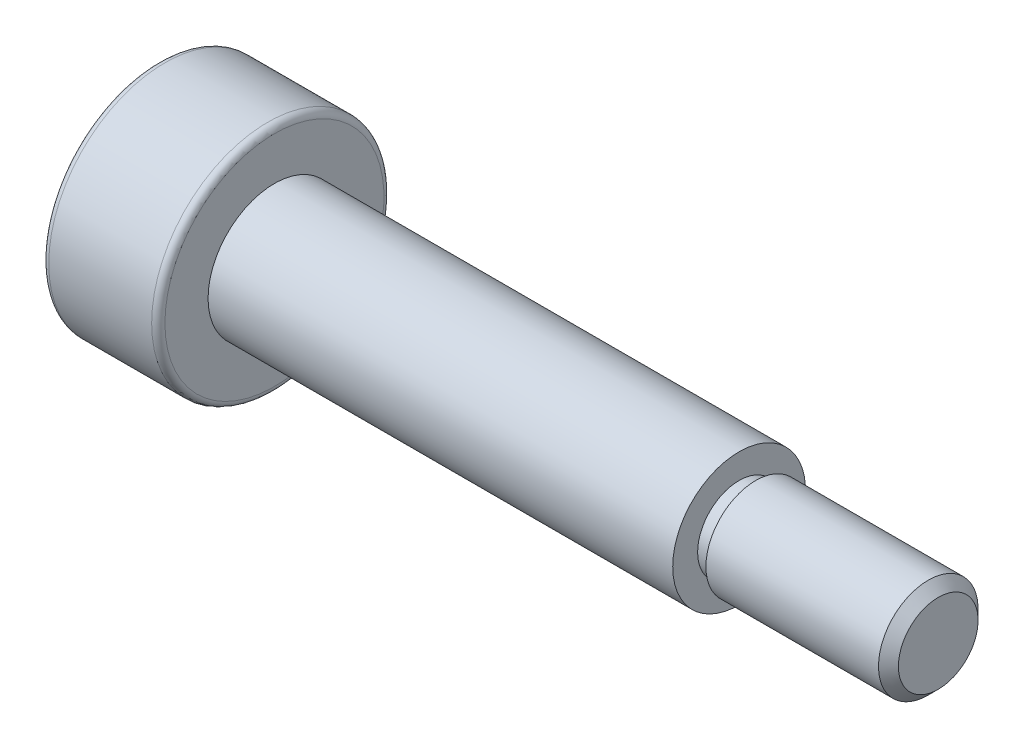
from build123d import *

# Parameters (mm, degrees)
FILLET_1_R          = 0.2
CHAMFER_1_SIZE      = 0.3
SKETCH_3_W          = 0.5
SKETCH_3_H          = 0.25
CUT_EXTRUDE_1_DEPTH = 2


with BuildPart() as part:
    # 草图1 → 旋转1 (revolve)
    with BuildSketch(Plane.XY):
        Polygon((-11.75, 0), (-11.75, 3.5), (-8.25, 3.5), (-8.25, 2), (5.75, 2), (5.75, 1.5), (11.75, 1.5), (11.75, 0), align=None)
    revolve(axis=Axis((-11.75, 0, 0), (1, 0, 0)))

    # 圆角1
    fillet_1_edges = [part.edges().sort_by_distance(p)[0] for p in [
        (-8.25, -3.5, 0),
        (-11.75, -3.5, 0),
    ]]
    fillet(fillet_1_edges, radius=FILLET_1_R)

    # 倒角1
    chamfer_1_edges = [part.edges().sort_by_distance(p)[0] for p in [
        (11.75, -1.5, 0),
    ]]
    chamfer(chamfer_1_edges, length=CHAMFER_1_SIZE)

    # 草图3 → 切除-旋转1 (revolve, cut)
    with BuildSketch(Plane.XY):
        with Locations((6, 1.375)):
            Rectangle(SKETCH_3_W, SKETCH_3_H)
    revolve(axis=Axis((5.75, 0, 0), (1, 0, 0)), mode=Mode.SUBTRACT)

    # 草图4 → 切除-拉伸1 (cut)
    with BuildSketch(Plane.ZY.offset(11.75)):
        Polygon((1.732050808, 0), (0.866025404, 1.5), (-0.866025404, 1.5), (-1.732050808, 0), (-0.866025404, -1.5), (0.866025404, -1.5), align=None)
    extrude(amount=-CUT_EXTRUDE_1_DEPTH, mode=Mode.SUBTRACT)


solid = part.part
